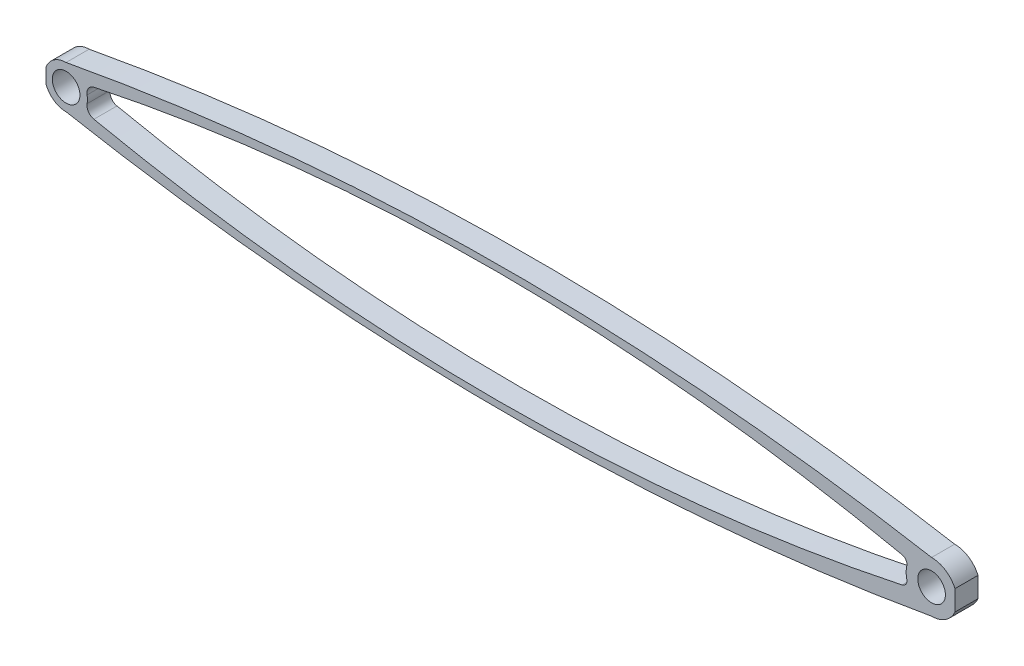
from build123d import *

# Parameters (mm, degrees)
SZKIC1_R                    = 4.635188213
SZKIC1_R_2                  = 3.000000079
SZKIC1_R_3                  = 5.522620658
DODANIE_WYCI_GNI_CIE1_DEPTH = 5
SZKIC2_W                    = 1.618528634
SZKIC2_H                    = 7.505645785
SZKIC2_W_2                  = 0.651830256
SZKIC2_H_2                  = 5.051684483
WYTNIJ_WYCI_GNI_CIE3_DEPTH  = 6


with BuildPart() as part:
    # Szkic1 → Dodanie-wyciągnięcie1 (new body)
    with BuildSketch(Plane.XY):
        with BuildLine():
            ThreePointArc((182.852037835, 2.527386464), (184.886505162, 4.714718212), (187.7624, 5.522620658))
            ThreePointArc((187.7624, 5.522620658), (93.841201508, 13.541760303), (0, 4.635188213))
            ThreePointArc((0, 4.635188213), (2.197225531, 4.081319607), (3.869348656, 2.552079691))
            ThreePointArc((3.869348656, 2.552079691), (4.951964009, 2.784051377), (6.035181021, 3.013197121))
            ThreePointArc((6.035181021, 3.013197121), (93.702955413, 12.084887853), (181.353491517, 2.8481265))
            ThreePointArc((181.353491517, 2.8481265), (182.102909488, 2.688433069), (182.852037835, 2.527386464))
        make_face()
        with BuildLine():
            ThreePointArc((0, -4.635188213), (93.841201508, -13.541760303), (187.7624, -5.522620658))
            ThreePointArc((187.7624, -5.522620658), (184.886505162, -4.714718212), (182.852037835, -2.527386464))
            ThreePointArc((182.852037835, -2.527386464), (182.102909488, -2.688433069), (181.353491517, -2.8481265))
            ThreePointArc((181.353491517, -2.8481265), (93.702955413, -12.084887853), (6.035181021, -3.013197121))
            ThreePointArc((6.035181021, -3.013197121), (4.951964009, -2.784051377), (3.869348656, -2.552079691))
            ThreePointArc((3.869348656, -2.552079691), (2.197225531, -4.081319607), (0, -4.635188213))
        make_face()
        Circle(SZKIC1_R)
        Circle(SZKIC1_R_2, mode=Mode.SUBTRACT)
        with BuildLine():
            ThreePointArc((4.561393731, -0.823806409), (4.303032237, -1.723044787), (3.869348656, -2.552079691))
            ThreePointArc((3.869348656, -2.552079691), (4.951964009, -2.784051377), (6.035181021, -3.013197121))
            ThreePointArc((6.035181021, -3.013197121), (4.853956333, -2.21760299), (4.561393731, -0.823806409))
        make_face()
        with BuildLine():
            ThreePointArc((6.035181021, 3.013197121), (4.951964009, 2.784051377), (3.869348656, 2.552079691))
            ThreePointArc((3.869348656, 2.552079691), (4.303032237, 1.723044787), (4.561393731, 0.823806409))
            ThreePointArc((4.561393731, 0.823806409), (4.853956333, 2.21760299), (6.035181021, 3.013197121))
        make_face()
        with BuildLine():
            ThreePointArc((181.353491517, -2.8481265), (182.102909488, -2.688433069), (182.852037835, -2.527386464))
            ThreePointArc((182.852037835, -2.527386464), (182.576004096, -1.897534311), (182.380388165, -1.238259886))
            ThreePointArc((182.380388165, -1.238259886), (182.204390831, -2.258445368), (181.353491517, -2.8481265))
        make_face()
        with Locations((187.7624, 0)):
            Circle(SZKIC1_R_3)
        with Locations((187.7624, 0)):
            Circle(SZKIC1_R_2, mode=Mode.SUBTRACT)
        with BuildLine():
            ThreePointArc((182.380388165, 1.238259886), (182.576004096, 1.897534311), (182.852037835, 2.527386464))
            ThreePointArc((182.852037835, 2.527386464), (182.102909488, 2.688433069), (181.353491517, 2.8481265))
            ThreePointArc((181.353491517, 2.8481265), (182.204390831, 2.258445368), (182.380388165, 1.238259886))
        make_face()
    extrude(amount=DODANIE_WYCI_GNI_CIE1_DEPTH)

    # Szkic2 → Wytnij-wyciągnięcie3 (cut, through all)
    with BuildSketch(Plane.XY):
        with Locations((193.638606269, 0.381285041)):
            Rectangle(SZKIC2_W, SZKIC2_H)
        with Locations((-4.682734605, -0.038745932)):
            Rectangle(SZKIC2_W_2, SZKIC2_H_2)
    extrude(amount=WYTNIJ_WYCI_GNI_CIE3_DEPTH, mode=Mode.SUBTRACT)


solid = part.part
